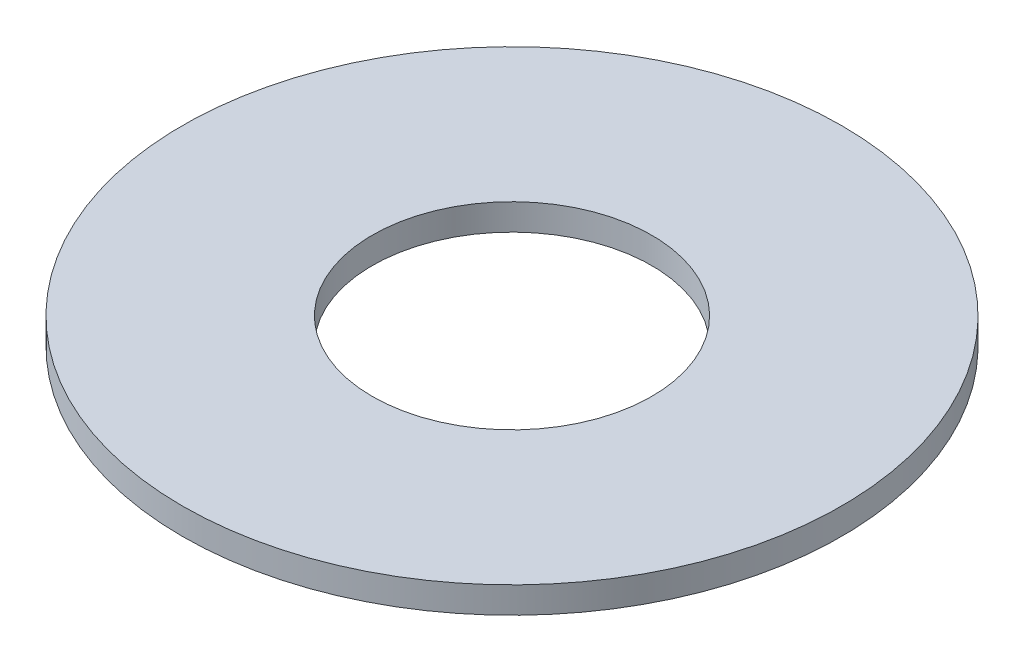
from build123d import *

# Parameters (mm, degrees)
SKETCH2_R           = 12.5
SKETCH2_R_2         = 5.3
BOSS_EXTRUDE1_DEPTH = 0.5


with BuildPart() as part:
    # Sketch2 → Boss-Extrude1 (new body, symmetric)
    with BuildSketch(Plane(origin=(0, 0, 0), x_dir=(1, 0, 0), z_dir=(0, 1, 0))):
        Circle(SKETCH2_R)
        Circle(SKETCH2_R_2, mode=Mode.SUBTRACT)
    extrude(amount=BOSS_EXTRUDE1_DEPTH, both=True)


solid = part.part
